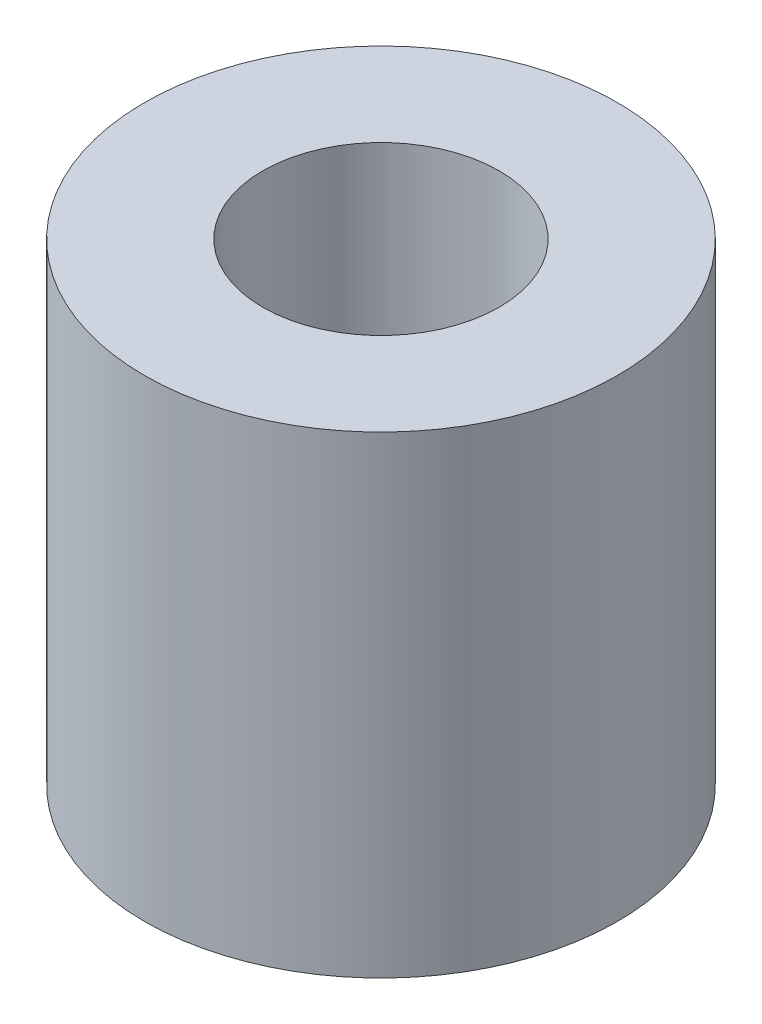
from build123d import *

# Parameters (mm, degrees)
SKETCH1_R           = 3.175
SKETCH1_R_2         = 1.5875
BOSS_EXTRUDE1_DEPTH = 6.35


with BuildPart() as part:
    # Sketch1 → Boss-Extrude1 (new body)
    with BuildSketch(Plane(origin=(0, 0, 0), x_dir=(1, 0, 0), z_dir=(0, 1, 0))):
        Circle(SKETCH1_R)
        Circle(SKETCH1_R_2, mode=Mode.SUBTRACT)
    extrude(amount=BOSS_EXTRUDE1_DEPTH)


solid = part.part
